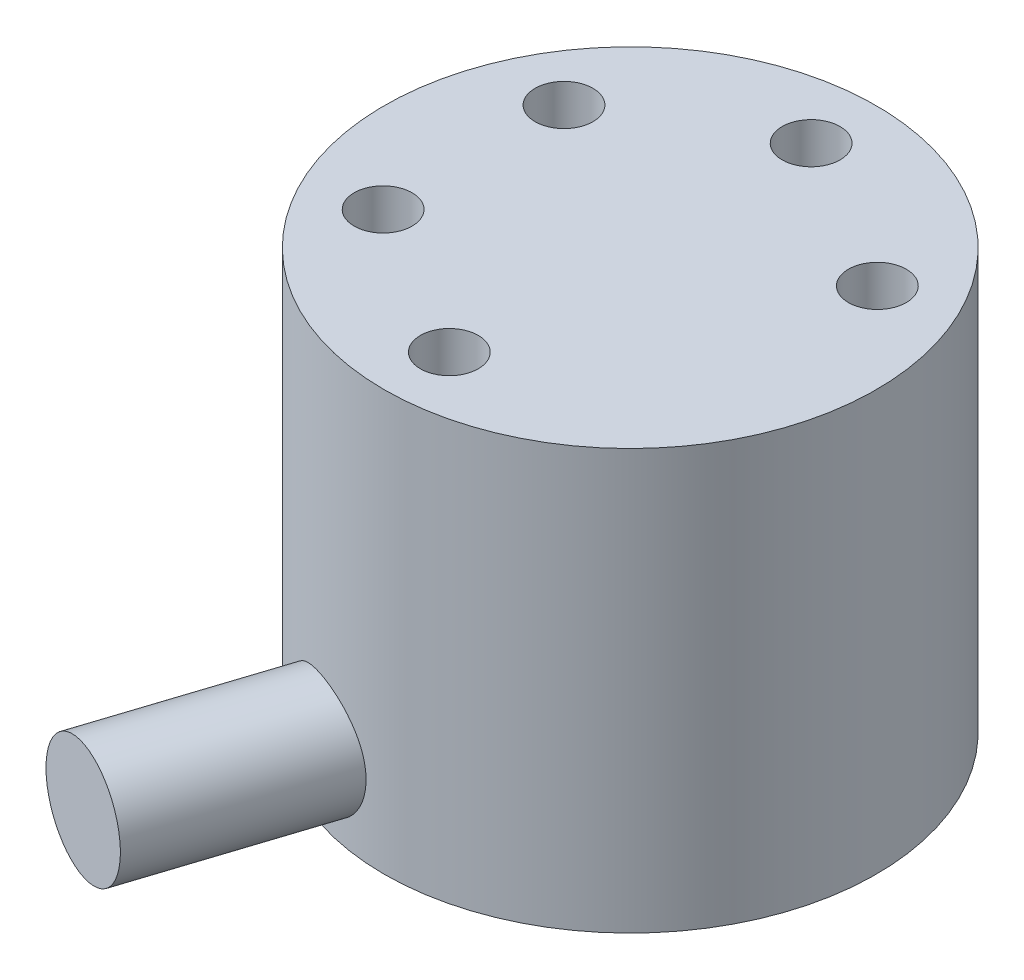
from build123d import *

# Parameters (mm, degrees)
SKETCH1_W                    = 8.5
SKETCH1_H                    = 14.5
CUT_EXTRUDE1_REACH           = 2.1
CUT_EXTRUDE2_REACH           = 2.1
CUT_EXTRUDE3_REACH           = 2.1
CUT_EXTRUDE4_REACH           = 2.1
F_2_0_2_DIAMETER_HOLE1_D     = 2
F_2_0_2_DIAMETER_HOLE1_DEPTH = 3
F_2_0_2_DIAMETER_HOLE2_D     = 2
F_2_0_2_DIAMETER_HOLE2_DEPTH = 3.5
F_2_0_2_DIAMETER_HOLE3_D     = 2
F_2_0_2_DIAMETER_HOLE3_DEPTH = 3
F_2_0_2_DIAMETER_HOLE4_D     = 2
F_2_0_2_DIAMETER_HOLE4_DEPTH = 3.5


with BuildPart() as part:
    # Sketch1 → Revolve1 (revolve)
    with BuildSketch(Plane(origin=(0, 0, 0), x_dir=(-1, 0, 0), z_dir=(0, 0, -1))):
        with Locations((-4.25, 7.25)):
            Rectangle(SKETCH1_W, SKETCH1_H)
    revolve(axis=Axis((0, 0, 0), (0, 1, 0)))

    # Sketch2 → Cut-Extrude1 (cut, up to next)
    with BuildSketch(Plane(origin=(-8.4, 0, 0), x_dir=(0, 0, -1), z_dir=(1, 0, 0)), mode=Mode.PRIVATE) as cut_extrude1_sk1:
        Polygon((0.9, 13.234042555), (0.9, 13.297872335), (0.649999993, 13.297872335), (0.649999993, 13.553191453), (0.587500007, 13.553191453), (0.587500007, 13.297872335), (0.3375, 13.297872335), (0.3375, 13.234042555), (0.587500007, 13.234042555), (0.587500007, 12.978723392), (0.649999993, 12.978723392), (0.649999993, 13.234042555), align=None)
    cut_extrude1_tool1 = extrude(cut_extrude1_sk1.sketch, amount=-CUT_EXTRUDE1_REACH, mode=Mode.PRIVATE) & part.part
    add(cut_extrude1_tool1.solids().sort_by_distance((-8.4, 13.265957, -0.61875))[0], mode=Mode.SUBTRACT)

    # Sketch3 → Cut-Extrude2 (cut, up to next)
    with BuildSketch(Plane.XY.offset(-8.4), mode=Mode.PRIVATE) as cut_extrude2_sk1:
        Polygon((1, 13.234042555), (1, 13.297872335), (0.749999993, 13.297872335), (0.749999993, 13.553191453), (0.687500007, 13.553191453), (0.687500007, 13.297872335), (0.4375, 13.297872335), (0.4375, 13.234042555), (0.687500007, 13.234042555), (0.687500007, 12.978723392), (0.749999993, 12.978723392), (0.749999993, 13.234042555), align=None)
    cut_extrude2_tool1 = extrude(cut_extrude2_sk1.sketch, amount=-CUT_EXTRUDE2_REACH, mode=Mode.PRIVATE) & part.part
    add(cut_extrude2_tool1.solids().sort_by_distance((0.71875, 13.265957, -8.4))[0], mode=Mode.SUBTRACT)

    # Sketch4 → Cut-Extrude3 (cut, up to next)
    with BuildSketch(Plane.XY.offset(-8.4), mode=Mode.PRIVATE) as cut_extrude3_sk1:
        Polygon((-0.875, 12.5), (-0.43749997, 13.106382996), (-3e-08, 12.5), (0.18749997, 12.5), (-0.34374997, 13.265957445), (0.18749997, 14), (-3e-08, 14), (-0.43749997, 13.393617004), (-0.875, 14), (-1.0625, 14), (-0.53125006, 13.265957445), (-1.0625, 12.5), align=None)
    cut_extrude3_tool1 = extrude(cut_extrude3_sk1.sketch, amount=-CUT_EXTRUDE3_REACH, mode=Mode.PRIVATE) & part.part
    add(cut_extrude3_tool1.solids().sort_by_distance((-0.4375, 13.242259, -8.4))[0], mode=Mode.SUBTRACT)

    # Sketch5 → Cut-Extrude4 (cut, up to next)
    with BuildSketch(Plane(origin=(-8.4, 0, 0), x_dir=(0, 0, -1), z_dir=(1, 0, 0)), mode=Mode.PRIVATE) as cut_extrude4_sk1:
        Polygon((-1.10000006, 14), (-0.6, 13.265957445), (-0.6, 12.5), (-0.4125, 12.5), (-0.4125, 13.265957445), (0.08749997, 14), (-0.10000003, 14), (-0.50625, 13.393617004), (-0.91250006, 14), align=None)
    cut_extrude4_tool1 = extrude(cut_extrude4_sk1.sketch, amount=-CUT_EXTRUDE4_REACH, mode=Mode.PRIVATE) & part.part
    add(cut_extrude4_tool1.solids().sort_by_distance((-8.4, 13.37564, 0.50625))[0], mode=Mode.SUBTRACT)

    # Sketch6 → Revolve2 (revolve)
    with BuildSketch(Plane(origin=(0, 2.49, 0), x_dir=(1, 0, 0), z_dir=(0, 1, 0))):
        Polygon((-6.537367948, -13.647813756), (-4.635254916, -14.265847744), (-2.552899345, -7.857016287), (-4.455012378, -7.238982298), align=None)
    revolve(axis=Axis((-4.635254916, 2.49, 14.265847744), (0.309016994, 0, -0.951056516)))

    # Ø2.0 (2) Diameter Hole1
    with Locations(Plane(origin=(0, 0, 0), x_dir=(-1, 0, 0), z_dir=(0, -1, 0))):
        with Locations((1.08530111, 6.155048456), (-5.87307888, -2.137625896)):
            Hole(F_2_0_2_DIAMETER_HOLE1_D / 2, depth=F_2_0_2_DIAMETER_HOLE1_DEPTH)

    # Ø2.0 (2) Diameter Hole2
    with Locations(Plane(origin=(0, 0, 0), x_dir=(-1, 0, 0), z_dir=(0, -1, 0))):
        with Locations((6.226216863, -0.544723392), (-3.584852727, -5.119700277), (-2.641364136, 5.664423669)):
            Hole(F_2_0_2_DIAMETER_HOLE2_D / 2, depth=F_2_0_2_DIAMETER_HOLE2_DEPTH)

    # Ø2.0 (2) Diameter Hole3
    with Locations(Plane(origin=(0, 14.5, 0), x_dir=(1, 0, 0), z_dir=(0, 1, 0))):
        with Locations((0, 6.25), (-5.412658774, -3.125)):
            Hole(F_2_0_2_DIAMETER_HOLE3_D / 2, depth=F_2_0_2_DIAMETER_HOLE3_DEPTH)

    # Ø2.0 (2) Diameter Hole4
    with Locations(Plane(origin=(0, 14.5, 0), x_dir=(1, 0, 0), z_dir=(0, 1, 0))):
        with Locations((0, -6.25), (5.412658774, 3.125), (-5.412658774, 3.125)):
            Hole(F_2_0_2_DIAMETER_HOLE4_D / 2, depth=F_2_0_2_DIAMETER_HOLE4_DEPTH)


solid = part.part
